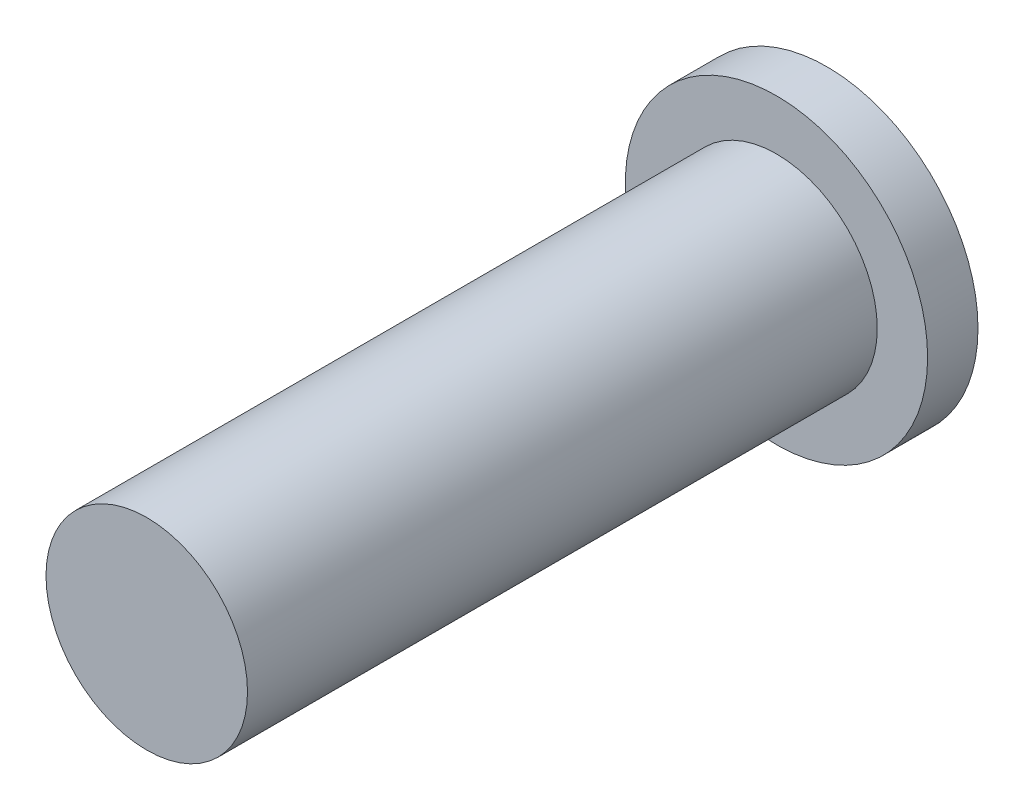
from build123d import *

# Parameters (mm, degrees)
SKETCH_1_R      = 6
EXTRUDE_1_DEPTH = 2
SKETCH_2_R      = 4
EXTRUDE_2_DEPTH = 25


with BuildPart() as part:
    # 草图1 → 凸台-拉伸1 (new body)
    with BuildSketch(Plane.XY):
        Circle(SKETCH_1_R)
    extrude(amount=EXTRUDE_1_DEPTH)

    # 草图2 → 凸台-拉伸2 (add)
    with BuildSketch(Plane.XY.offset(2)):
        Circle(SKETCH_2_R)
    extrude(amount=EXTRUDE_2_DEPTH)


solid = part.part
